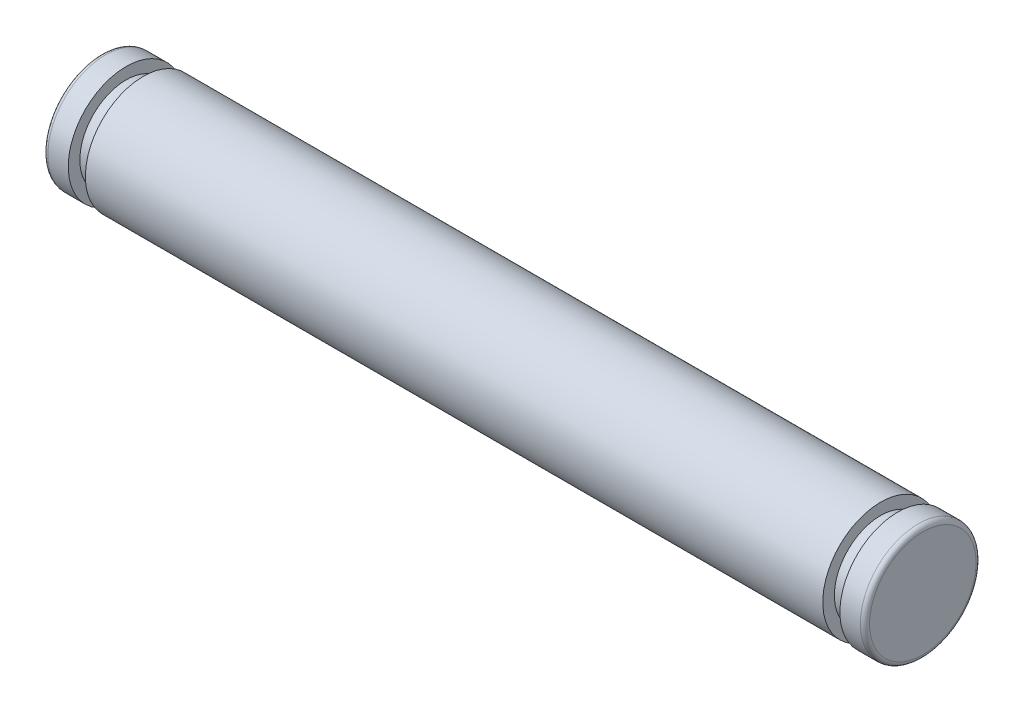
from build123d import *


with BuildPart() as part:
    # Sketch1 → Revolve1 (revolve)
    with BuildSketch(Plane(origin=(0, 0, 0), x_dir=(1, 0, 0), z_dir=(0, 1, 0))):
        with BuildLine():
            Line((-15.927, 2.5), (15.927, 2.5))
            Line((15.927, 2.5), (15.927, 2))
            Line((15.927, 2), (16.667, 2))
            Line((16.667, 2), (16.667, 2.5))
            Line((16.667, 2.5), (17.55, 2.5))
            ThreePointArc((17.55, 2.5), (17.691421356, 2.441421356), (17.75, 2.3))
            Line((17.75, 2.3), (17.75, 0))
            Line((17.75, 0), (-17.75, 0))
            Line((-17.75, 0), (-17.75, 2.3))
            ThreePointArc((-17.75, 2.3), (-17.691421356, 2.441421356), (-17.55, 2.5))
            Line((-17.55, 2.5), (-16.667, 2.5))
            Line((-16.667, 2.5), (-16.667, 2))
            Line((-16.667, 2), (-15.927, 2))
            Line((-15.927, 2), (-15.927, 2.5))
        make_face()
    revolve(axis=Axis((17.75, 0, 0), (-1, 0, 0)))


solid = part.part
